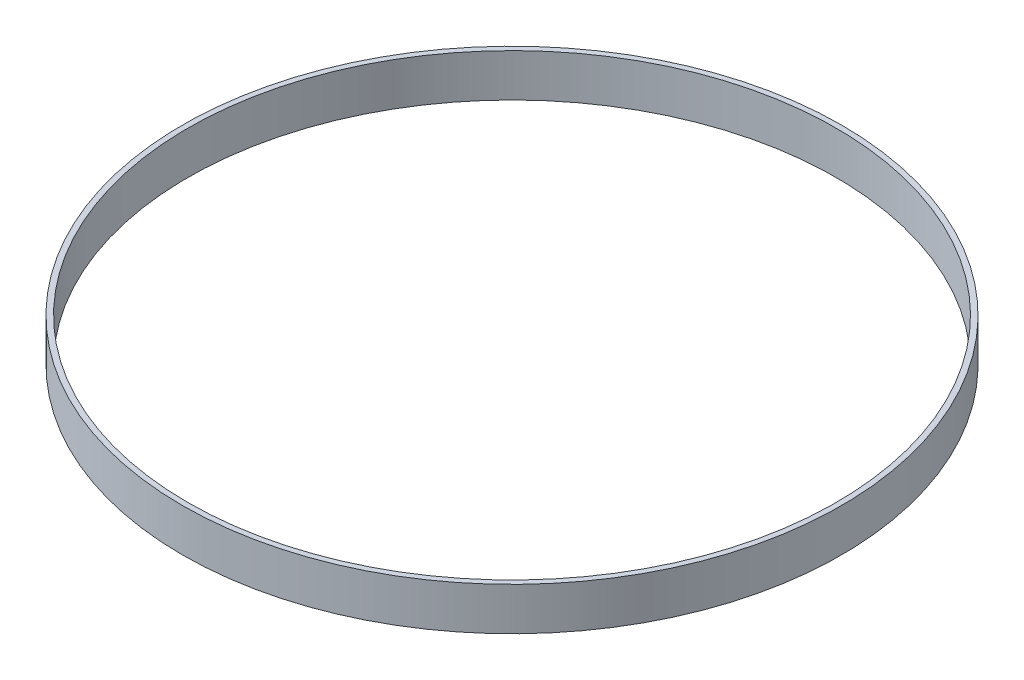
from build123d import *

# Parameters (mm, degrees)
SKETCH1_R           = 97.79
SKETCH1_R_2         = 96.2025
BOSS_EXTRUDE1_DEPTH = 12.7


with BuildPart() as part:
    # Sketch1 → Boss-Extrude1 (new body)
    with BuildSketch(Plane(origin=(0, 0, 0), x_dir=(1, 0, 0), z_dir=(0, 1, 0))):
        Circle(SKETCH1_R)
        Circle(SKETCH1_R_2, mode=Mode.SUBTRACT)
    extrude(amount=BOSS_EXTRUDE1_DEPTH)


solid = part.part
